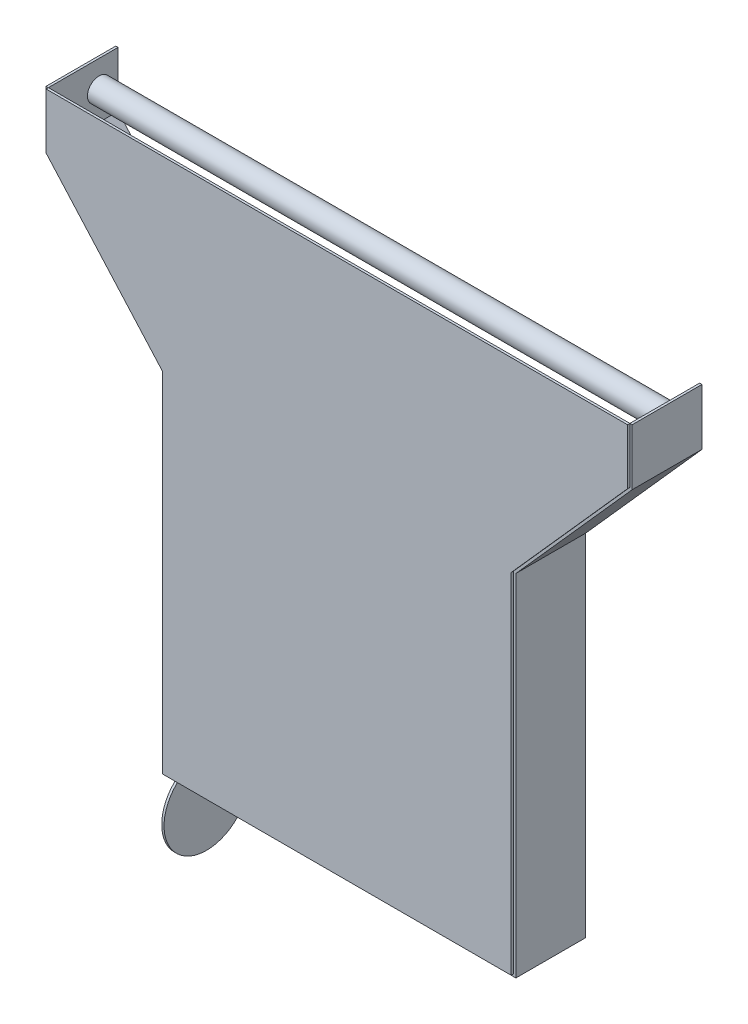
from build123d import *

# Parameters (mm, degrees)
BOSS_EXTRUDE1_DEPTH = 2.54
EXTRUDE_THIN1_DEPTH = 76.2
BOSS_EXTRUDE4_REACH = 806.751
SKETCH5_R           = 12.7
SKETCH9_R           = 46.40857606
BOSS_EXTRUDE6_DEPTH = 2.54


with BuildPart() as part:
    # Sketch1 → Boss-Extrude1 (new body)
    with BuildSketch(Plane.XY):
        Polygon((190.5, -101.6), (317.5, 41.095782204), (317.5, 101.6), (-317.5, 101.6), (-317.5, 41.095782204), (-190.5, -101.6), (-190.5, -482.6), (190.5, -482.6), align=None)
    extrude(amount=BOSS_EXTRUDE1_DEPTH)


with BuildPart() as body_2:
    # Sketch4 → Extrude-Thin1 (new body)
    with BuildSketch(Plane(origin=(0, 0, 0), x_dir=(-1, 0, 0), z_dir=(0, 0, -1))):
        Polygon((-317.5, 101.6), (-317.5, 41.095782204), (-190.5, -101.6), (-190.5, -482.6), (190.5, -482.6), (190.5, -101.6), (317.5, 41.095782204), (317.5, 101.6), (320.04, 101.6), (320.04, 40.129169808), (193.04, -102.566612396), (193.04, -485.14), (-193.04, -485.14), (-193.04, -102.566612396), (-320.04, 40.129169808), (-320.04, 101.6), align=None)
    extrude(amount=EXTRUDE_THIN1_DEPTH)

    # Sketch5 → Boss-Extrude4 (add, up to next)
    with BuildSketch(Plane(origin=(-317.5, 0, 0), x_dir=(0, 0, -1), z_dir=(1, 0, 0)), mode=Mode.PRIVATE) as boss_extrude4_sk1:
        with Locations((55.364828068, 72.288057332)):
            Circle(SKETCH5_R)
    boss_extrude4_tool1 = extrude(boss_extrude4_sk1.sketch, amount=BOSS_EXTRUDE4_REACH, mode=Mode.PRIVATE) - body_2.part
    add(boss_extrude4_tool1.solids().sort_by_distance((-317.5, 72.288057, -55.364828))[0])


with BuildPart() as body_3:
    # Sketch9 → Boss-Extrude6 (new body)
    with BuildSketch(Plane(origin=(-190.5, -297.860084408, 89.625050191), x_dir=(0, 0, -1), z_dir=(1, 0, 0))):
        with Locations((132.823064522, -232.306086863)):
            Circle(SKETCH9_R)
    extrude(amount=BOSS_EXTRUDE6_DEPTH)


solid = Compound([part.part, body_2.part, body_3.part])
